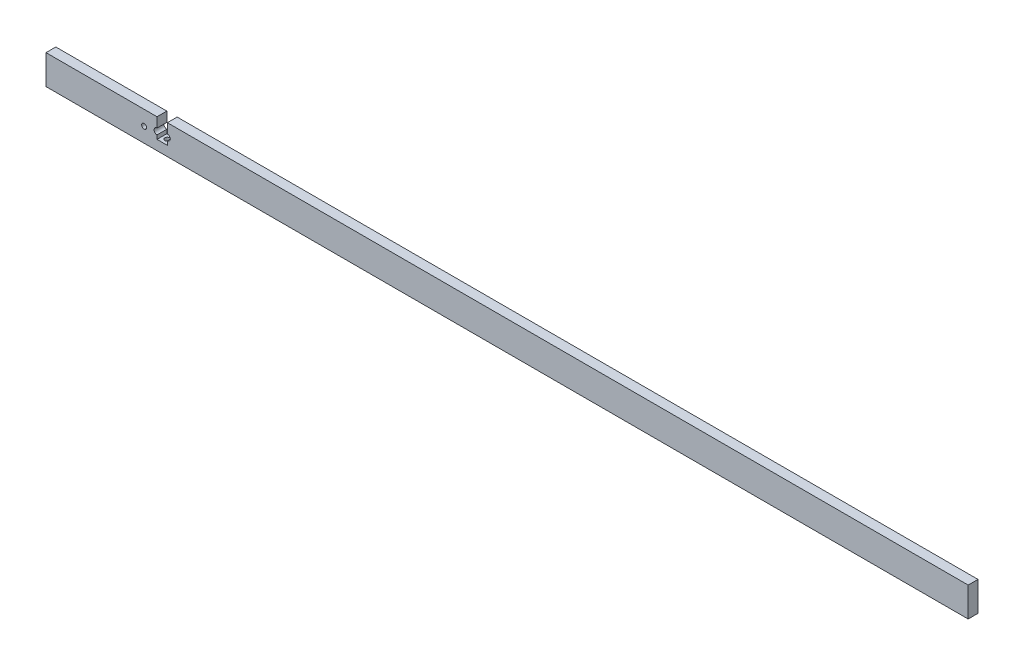
from build123d import *

# Parameters (mm, degrees)
ESQUISSE1_W             = 470
ESQUISSE1_H             = 15
BOSS_EXTRU_1_DEPTH      = 5
ESQUISSE2_R             = 1.25
ENL_V_MAT_EXTRU_1_DEPTH = 6
ESQUISSE3_W             = 5.25
ESQUISSE3_H             = 10
ENL_V_MAT_EXTRU_2_DEPTH = 6
ESQUISSE4_R             = 1.25
ENL_V_MAT_EXTRU_3_DEPTH = 10
ENL_V_MAT_EXTRU_4_DEPTH = 10


with BuildPart() as part:
    # Esquisse1 → Boss.-Extru.1 (new body)
    with BuildSketch(Plane.XY):
        Rectangle(ESQUISSE1_W, ESQUISSE1_H)
    extrude(amount=BOSS_EXTRU_1_DEPTH)

    # Esquisse2 → Enlèv. mat.-Extru.1 (cut, through all)
    with BuildSketch(Plane.XY.offset(5)):
        with Locations((-185, 0)):
            Circle(ESQUISSE2_R)
    extrude(amount=-ENL_V_MAT_EXTRU_1_DEPTH, mode=Mode.SUBTRACT)

    # Esquisse3 → Enlèv. mat.-Extru.2 (cut, through all)
    with BuildSketch(Plane.XY.offset(5)):
        with Locations((-175.785038425, 2.5)):
            Rectangle(ESQUISSE3_W, ESQUISSE3_H)
    extrude(amount=-ENL_V_MAT_EXTRU_2_DEPTH, mode=Mode.SUBTRACT)

    # Esquisse4 → Enlèv. mat.-Extru.3 (cut)
    with BuildSketch(Plane(origin=(0, -7.5, 0), x_dir=(-1, 0, 0), z_dir=(0, -1, 0))):
        with Locations(Location((175.910038425, -2.312700885, 0), (0, 0, 180))):  # turned: the seam where the file's is
            Circle(ESQUISSE4_R)
    extrude(amount=-ENL_V_MAT_EXTRU_3_DEPTH, mode=Mode.SUBTRACT)

    # Esquisse5 → Enlèv. mat.-Extru.4 (cut)
    with BuildSketch(Plane.XY.offset(5)):
        with BuildLine():
            Line((-178.410038425, 2.5), (-178.410038425, -0.5))
            ThreePointArc((-178.410038425, -0.5), (-179.910038425, 1), (-178.410038425, 2.5))
        make_face()
        with BuildLine():
            Line((-173.160038425, 2.5), (-173.160038425, -0.5))
            ThreePointArc((-173.160038425, -0.5), (-171.660038425, 1), (-173.160038425, 2.5))
        make_face()
    extrude(amount=-ENL_V_MAT_EXTRU_4_DEPTH, mode=Mode.SUBTRACT)


solid = part.part
